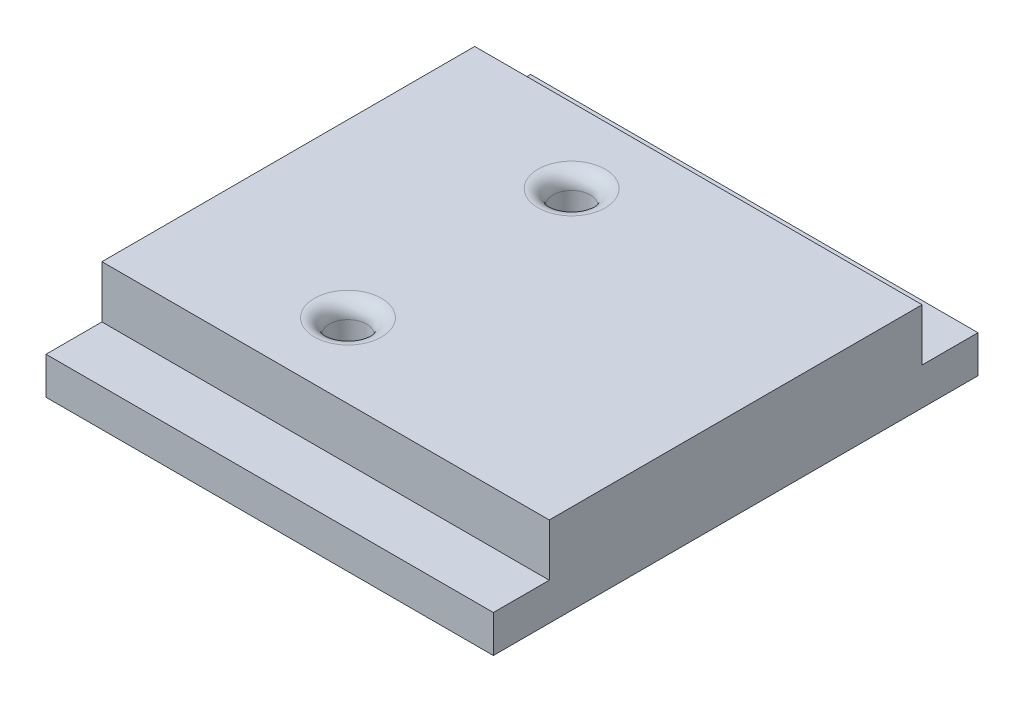
from build123d import *

# Parameters (mm, degrees)
BOSS_EXTRUDE1_DEPTH     = 60
SKETCH2_R               = 2.5
CUT_EXTRUDE1_DEPTH      = 1
CUT_EXTRUDE1_DEPTH_BACK = 13
FILLET1_R               = 2


with BuildPart() as part:
    # Sketch1 → Boss-Extrude1 (new body)
    with BuildSketch(Plane(origin=(0, 0, 0), x_dir=(0, 0, -1), z_dir=(1, 0, 0))):
        Polygon((-50, 0), (0, 0), (0, -7), (7.5, -7), (7.5, -12), (-57.5, -12), (-57.5, -7), (-50, -7), align=None)
    extrude(amount=BOSS_EXTRUDE1_DEPTH)

    # Sketch2 → Cut-Extrude1 (cut, two sides)
    with BuildSketch(Plane(origin=(0, 0, 0), x_dir=(1, 0, 0), z_dir=(0, 1, 0))) as cut_extrude1_sk:
        with Locations((23, -10)):
            Circle(SKETCH2_R)
        with Locations((23, -40)):
            Circle(SKETCH2_R)
    extrude(amount=CUT_EXTRUDE1_DEPTH, mode=Mode.SUBTRACT)
    extrude(cut_extrude1_sk.sketch, amount=-CUT_EXTRUDE1_DEPTH_BACK, mode=Mode.SUBTRACT)

    # Fillet1
    fillet1_edges = [part.edges().sort_by_distance(p)[0] for p in [
        (20.5, 0, 10),
        (20.5, 0, 40),
    ]]
    fillet(fillet1_edges, radius=FILLET1_R)


solid = part.part
